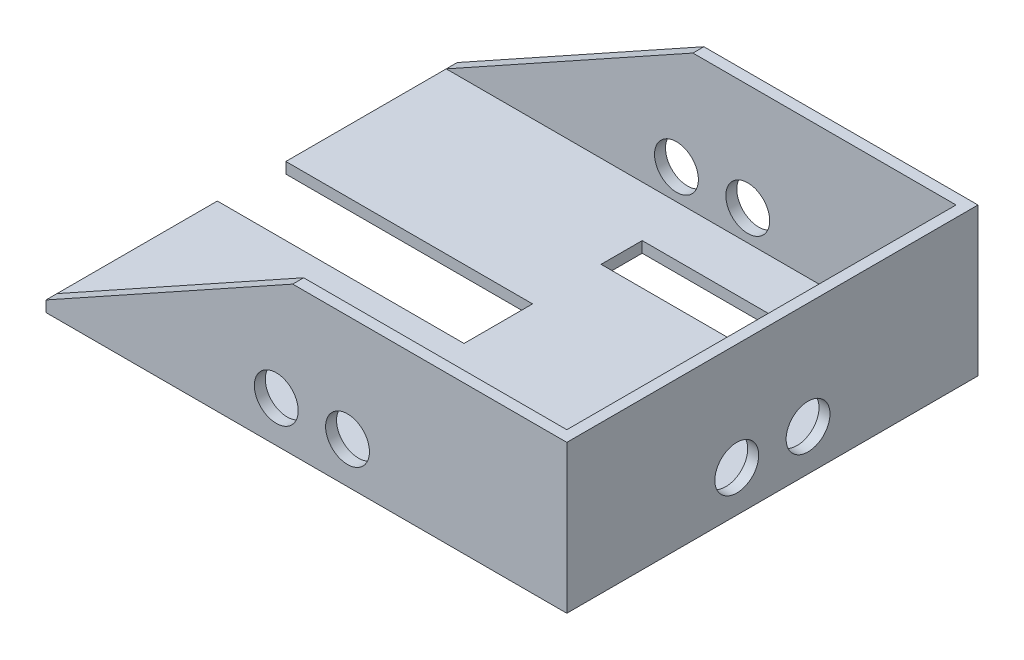
from build123d import *

# Parameters (mm, degrees)
BOSS_EXTRUDE1_DEPTH = 4
BOSS_EXTRUDE2_DEPTH = 4
SKETCH3_W           = 142
SKETCH3_H           = 50
BOSS_EXTRUDE3_DEPTH = 4
SKETCH4_W           = 80
SKETCH4_H           = 15
CUT_EXTRUDE1_DEPTH  = 4
SKETCH5_R           = 8
CUT_EXTRUDE2_DEPTH  = 4
SKETCH6_R           = 8
CUT_EXTRUDE3_DEPTH  = 4


with BuildPart() as part:
    # Sketch1 → Boss-Extrude1 (new body)
    with BuildSketch(Plane(origin=(0, 0, 0), x_dir=(1, 0, 0), z_dir=(0, 1, 0))):
        Polygon((-5, -12.5), (-5, 12.5), (-95, 12.5), (-95, 75), (95, 75), (95, -75), (-95, -75), (-95, -12.5), align=None)
    extrude(amount=BOSS_EXTRUDE1_DEPTH)

    # Sketch2 → Boss-Extrude2 (add)
    with BuildSketch(Plane.XY.offset(75)):
        Polygon((95, 4), (95, 54), (-5, 54), (-95, 4), align=None)
    boss_extrude2 = extrude(amount=-BOSS_EXTRUDE2_DEPTH)

    # Mirror1: Boss-Extrude2 across plane
    add(boss_extrude2.mirror(Plane.XY))

    # Sketch3 → Boss-Extrude3 (add)
    with BuildSketch(Plane(origin=(95, 0, 0), x_dir=(0, 0, -1), z_dir=(1, 0, 0))):
        with Locations((0, 29)):
            Rectangle(SKETCH3_W, SKETCH3_H)
    extrude(amount=-BOSS_EXTRUDE3_DEPTH)

    # Sketch4 → Cut-Extrude1 (cut)
    with BuildSketch(Plane.XZ):
        with Locations((35, 45)):
            Rectangle(SKETCH4_W, SKETCH4_H)
    cut_extrude1 = extrude(amount=-CUT_EXTRUDE1_DEPTH, mode=Mode.SUBTRACT)

    # Mirror2: Cut-Extrude1 across plane
    add(cut_extrude1.mirror(Plane.XY), mode=Mode.SUBTRACT)

    # Sketch5 → Cut-Extrude2 (cut)
    with BuildSketch(Plane(origin=(95, 0, 0), x_dir=(0, 0, -1), z_dir=(1, 0, 0))):
        with Locations((-13, 15)):
            Circle(SKETCH5_R)
        with Locations((13, 15)):
            Circle(SKETCH5_R)
    extrude(amount=-CUT_EXTRUDE2_DEPTH, mode=Mode.SUBTRACT)

    # Sketch6 → Cut-Extrude3 (cut)
    with BuildSketch(Plane(origin=(0, 0, -75), x_dir=(-1, 0, 0), z_dir=(0, 0, -1))):
        with Locations((-15, 15)):
            Circle(SKETCH6_R)
        with Locations((11, 15)):
            Circle(SKETCH6_R)
    cut_extrude3 = extrude(amount=-CUT_EXTRUDE3_DEPTH, mode=Mode.SUBTRACT)

    # Mirror3: Cut-Extrude3 across plane
    add(cut_extrude3.mirror(Plane.XY), mode=Mode.SUBTRACT)


solid = part.part
